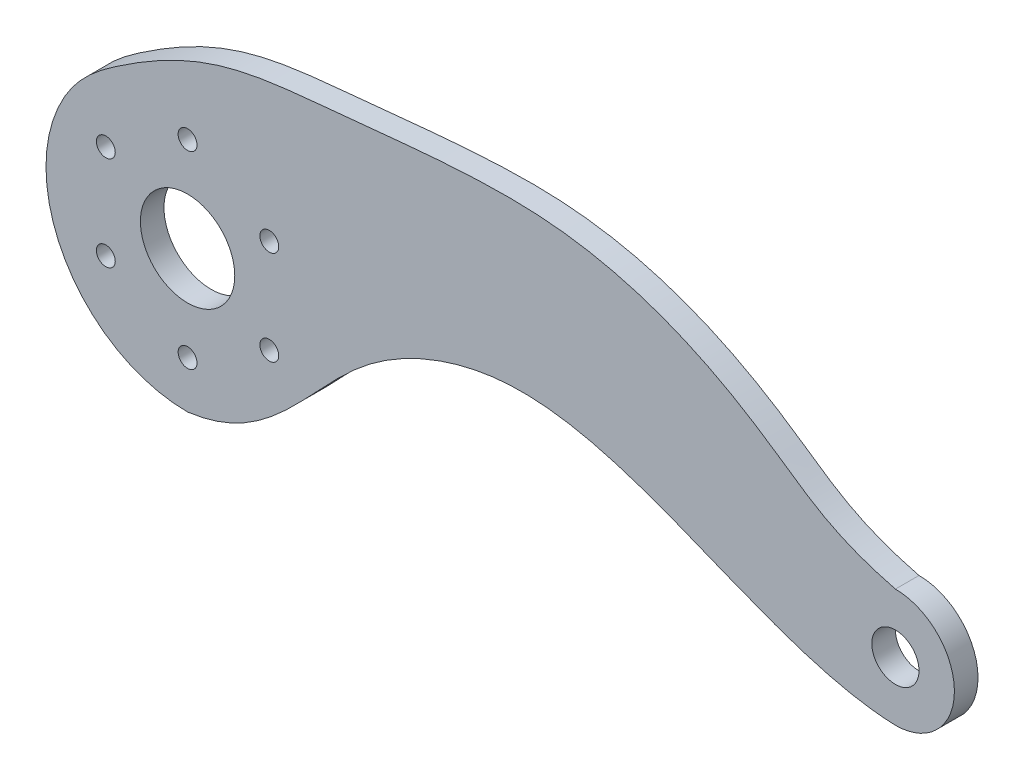
from build123d import *

# Parameters (mm, degrees)
SKETCH1_R           = 5
SKETCH1_R_2         = 10
BOSS_EXTRUDE3_DEPTH = 5


with BuildPart() as part:
    # Sketch1 → Boss-Extrude3 (new body)
    with BuildSketch(Plane.XY):
        with BuildLine():
            add(Edge.make_bspline(
                [(-26.063461661, 14.855839466), (-22.995207495, 20.238862419), (-18.617864266, 23.494747377), (-14.633714845, 26.188821849)],
                knots=[0, 0, 0, 0, 0.056043779, 0.056043779, 0.056043779, 0.056043779], degree=3))
            ThreePointArc((-26.063461661, 14.855839466), (-25.939113169, -15.071907909), (0, -30))
            add(Edge.make_bspline(
                [(0, -30), (17.93675339, -27.745895163), (30.170167076, -2.352031791), (85.215870065, 19.611994815), (122.19936238, -11.53423425), (150, -12.5)],
                knots=[0, 0, 0, 0, 0.288188908, 0.475939829, 1, 1, 1, 1], degree=3))
            ThreePointArc((150, -12.5), (154.015063849, -11.837620635), (157.604608427, -9.920681966))
            add(Edge.make_bspline(
                [(157.604608427, -9.920681966), (158.523147842, -9.170588579), (159.428456142, -8.206961361)],
                knots=[0.991193685, 0.991193685, 0.991193685, 1, 1, 1], degree=2))
            ThreePointArc((159.428456142, -8.206961361), (162.5, 0), (159.428456142, 8.206961361))
            ThreePointArc((159.428456142, 8.206961361), (159.074763389, 8.59643353), (158.704995258, 8.970677653))
            ThreePointArc((158.704995258, 8.970677653), (154.696622688, 11.584115647), (150, 12.5))
            add(Edge.make_bspline(
                [(-14.633714845, 26.188821849), (4.471910737, 39.10801054), (20.159751535, 39.107737434), (86.741615763, 46.999815307), (125.812924925, 25.830072722), (135.882657692, 16.075482759), (150, 12.5)],
                knots=[0.056043779, 0.056043779, 0.056043779, 0.056043779, 0.324796613, 0.474987684, 0.725167046, 0.945335071, 0.945335071, 0.945335071, 0.945335071], degree=3))
        make_face()
        with BuildLine():
            ThreePointArc((18.232654753, 8.220115611), (19.553172314, 4.203980551), (20, 0))
            ThreePointArc((20, 0), (19.553172314, -4.203980551), (18.232654753, -8.220115611))
            ThreePointArc((18.232654753, -8.220115611), (19.027009373, -8.956997928), (19.320508076, -10))
            ThreePointArc((19.320508076, -10), (18.276880515, -11.756516939), (16.235156318, -11.679884389))
            ThreePointArc((16.235156318, -11.679884389), (10, -17.320508076), (1.997498436, -19.9))
            ThreePointArc((1.997498436, -19.9), (1.999374511, -19.949984358), (2, -20))
            ThreePointArc((2, -20), (-0.050015642, -21.999374511), (-1.997498436, -19.9))
            ThreePointArc((-1.997498436, -19.9), (-10, -17.320508076), (-16.235156318, -11.679884389))
            ThreePointArc((-16.235156318, -11.679884389), (-19.052558883, -11), (-18.232654753, -8.220115611))
            ThreePointArc((-18.232654753, -8.220115611), (-20, 0), (-18.232654753, 8.220115611))
            ThreePointArc((-18.232654753, 8.220115611), (-19.052558883, 11), (-16.235156318, 11.679884389))
            ThreePointArc((-16.235156318, 11.679884389), (-10, 17.320508076), (-1.997498436, 19.9))
            ThreePointArc((-1.997498436, 19.9), (-0.050015642, 21.999374511), (2, 20))
            ThreePointArc((2, 20), (1.999374511, 19.949984358), (1.997498436, 19.9))
            ThreePointArc((1.997498436, 19.9), (10, 17.320508076), (16.235156318, 11.679884389))
            ThreePointArc((16.235156318, 11.679884389), (18.276880515, 11.756516939), (19.320508076, 10))
            ThreePointArc((19.320508076, 10), (19.027009373, 8.956997928), (18.232654753, 8.220115611))
        make_face(mode=Mode.SUBTRACT)
        with Locations((150, 0)):
            Circle(SKETCH1_R, mode=Mode.SUBTRACT)
        with BuildLine():
            ThreePointArc((18.232654753, -8.220115611), (19.553172314, -4.203980551), (20, 0))
            ThreePointArc((20, 0), (19.553172314, 4.203980551), (18.232654753, 8.220115611))
            ThreePointArc((18.232654753, 8.220115611), (15.588457268, 9), (16.235156318, 11.679884389))
            ThreePointArc((16.235156318, 11.679884389), (10, 17.320508076), (1.997498436, 19.9))
            ThreePointArc((1.997498436, 19.9), (0, 18), (-1.997498436, 19.9))
            ThreePointArc((-1.997498436, 19.9), (-10, 17.320508076), (-16.235156318, 11.679884389))
            ThreePointArc((-16.235156318, 11.679884389), (-15.563991136, 10.956372439), (-15.320508076, 10))
            ThreePointArc((-15.320508076, 10), (-16.277506003, 8.293498703), (-18.232654753, 8.220115611))
            ThreePointArc((-18.232654753, 8.220115611), (-20, 0), (-18.232654753, -8.220115611))
            ThreePointArc((-18.232654753, -8.220115611), (-16.277506003, -8.293498703), (-15.320508076, -10))
            ThreePointArc((-15.320508076, -10), (-15.563991136, -10.956372439), (-16.235156318, -11.679884389))
            ThreePointArc((-16.235156318, -11.679884389), (-10, -17.320508076), (-1.997498436, -19.9))
            ThreePointArc((-1.997498436, -19.9), (0, -18), (1.997498436, -19.9))
            ThreePointArc((1.997498436, -19.9), (10, -17.320508076), (16.235156318, -11.679884389))
            ThreePointArc((16.235156318, -11.679884389), (15.588457268, -9), (18.232654753, -8.220115611))
        make_face()
        Circle(SKETCH1_R_2, mode=Mode.SUBTRACT)
    extrude(amount=BOSS_EXTRUDE3_DEPTH)


solid = part.part
